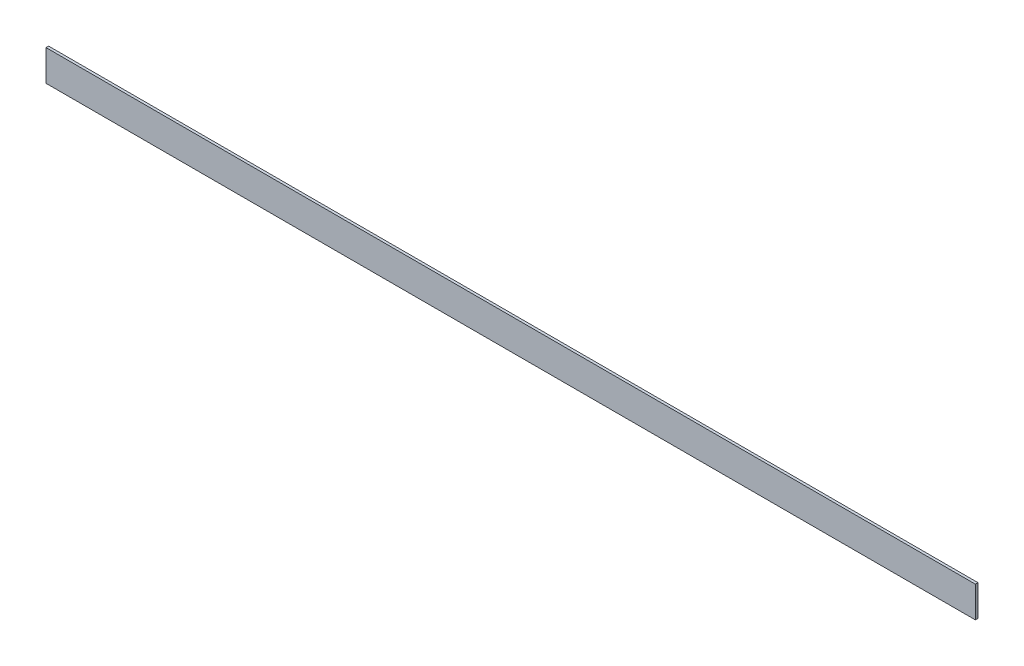
from build123d import *

# Parameters (mm, degrees)
SKETCH1_W           = 6.35
SKETCH1_H           = 76.2
BOSS_EXTRUDE1_DEPTH = 2286


with BuildPart() as part:
    # Sketch1 → Boss-Extrude1 (new body)
    with BuildSketch(Plane(origin=(0, 0, 0), x_dir=(0, 0, -1), z_dir=(1, 0, 0))):
        Rectangle(SKETCH1_W, SKETCH1_H)
    extrude(amount=BOSS_EXTRUDE1_DEPTH)


solid = part.part
